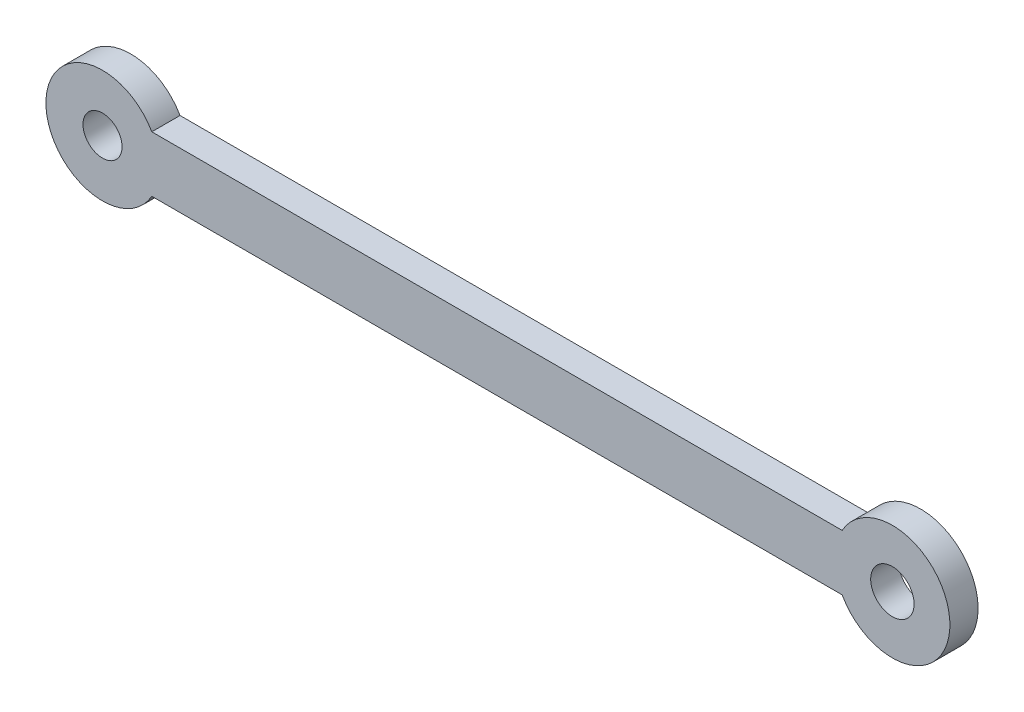
from build123d import *

# Parameters (mm, degrees)
SKETCH1_R           = 2.19347965
SKETCH1_R_2         = 2.440229405
BOSS_EXTRUDE1_DEPTH = 3.175


with BuildPart() as part:
    # Sketch1 → Boss-Extrude1 (new body)
    with BuildSketch(Plane.XY):
        with BuildLine():
            Line((-51.974034985, 17.724715306), (25.646533636, 17.724715306))
            ThreePointArc((25.646533636, 17.724715306), (37.757336251, 14.585963637), (25.646533636, 11.447211968))
            Line((25.646533636, 11.447211968), (-51.974034985, 11.447211968))
            ThreePointArc((-51.974034985, 11.447211968), (-63.879482412, 14.585963637), (-51.974034985, 17.724715306))
        make_face()
        with Locations((-57.513008519, 14.585963637)):
            Circle(SKETCH1_R, mode=Mode.SUBTRACT)
        with Locations((31.295200462, 14.585963637)):
            Circle(SKETCH1_R_2, mode=Mode.SUBTRACT)
    extrude(amount=BOSS_EXTRUDE1_DEPTH)


solid = part.part
